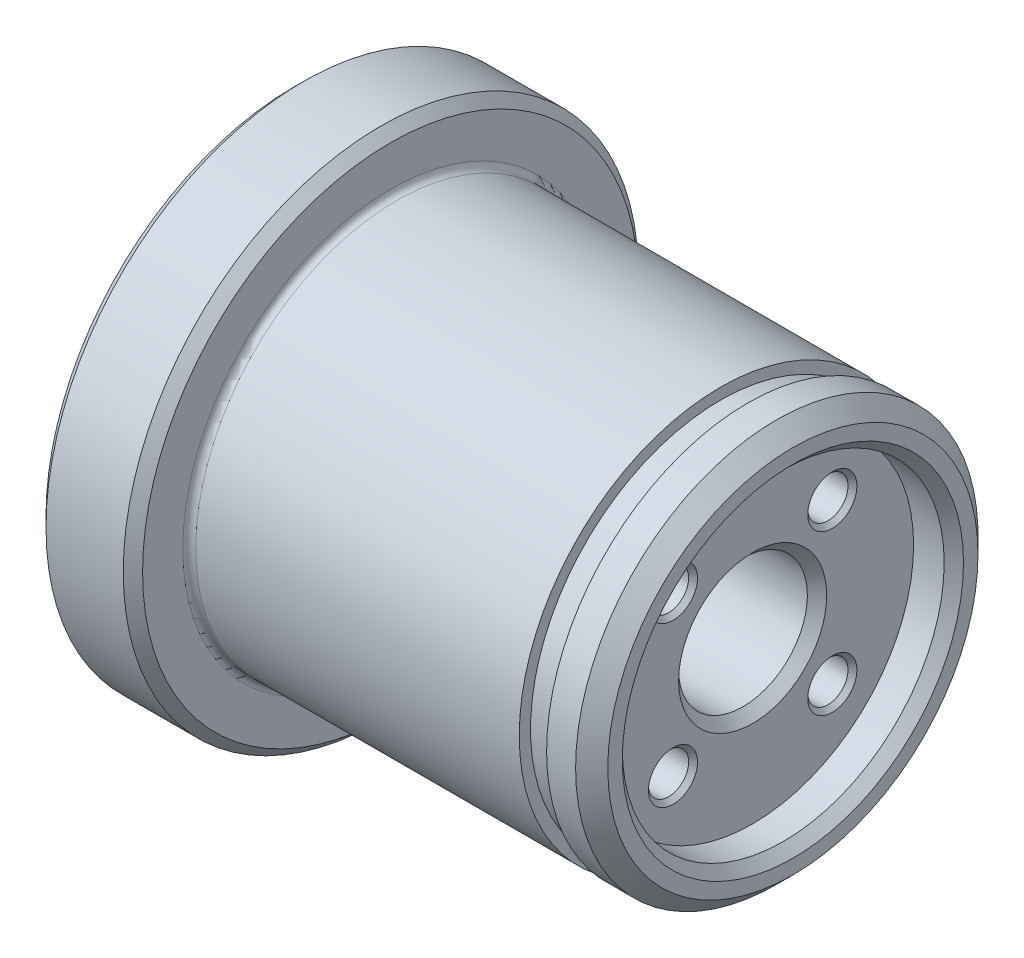
from build123d import *

# Parameters (mm, degrees)
SKETCH_2_W               = 1.7
SKETCH_2_H               = 0.7
CHAMFER_1_SIZE           = 1
FILLET_1_R               = 0.4
SKETCH_5_W               = 2.5
SKETCH_5_H               = 10
PATTERN_CIRCULAR_1_COUNT = 4
CHAMFER_2_SIZE           = 0.6
SKETCH_6_W               = 31
SKETCH_6_H               = 4
CHAMFER_3_SIZE           = 0.6
PATTERN_CIRCULAR_2_COUNT = 4
CHAMFER_4_SIZE           = 0.6


with BuildPart() as part:
    # Эскиз1 → Повернуть1 (revolve)
    with BuildSketch(Plane.XY):
        Polygon((0, 0), (0, 12.5), (-25, 12.5), (-25, 16), (-31, 16), (-31, 0), align=None)
    revolve(axis=Axis((0, 0, 0), (1, 0, 0)))

    # Эскиз2 → Вырез-Повернуть1 (revolve, cut)
    with BuildSketch(Plane.XY):
        with Locations((-3.65, 12.15)):
            Rectangle(SKETCH_2_W, SKETCH_2_H)
    revolve(axis=Axis((0, 0, 0), (-1, 0, 0)), mode=Mode.SUBTRACT)

    # Фаска1
    chamfer_1_edges = [part.edges().sort_by_distance(p)[0] for p in [
        (0, -12.5, 0),
    ]]
    chamfer(chamfer_1_edges, length=CHAMFER_1_SIZE)

    # Скругление1
    fillet_1_edges = [part.edges().sort_by_distance(p)[0] for p in [
        (-25, -12.5, 0),
    ]]
    fillet(fillet_1_edges, radius=FILLET_1_R)

    # Эскиз5 → Вырез-Повернуть2 (revolve, cut)
    with BuildSketch(Plane.XY):
        with Locations((-1.25, 5)):
            Rectangle(SKETCH_5_W, SKETCH_5_H)
    revolve(axis=Axis((0, 0, 0), (-1, 0, 0)), mode=Mode.SUBTRACT)

    # Эскиз4 → Отверстие обработанное метчиком M31 (revolve, cut)
    with BuildSketch(Plane(origin=(-2.5, 4.949747468, -4.949747468), x_dir=(0, 0, -1), z_dir=(0, 1, 0))):
        Polygon((0, 0), (0, 7.751075774), (1.25, 7), (1.25, 0.275), (1.525, 0), align=None)
    hole_wizard_m31 = revolve(axis=Axis((3.85, 4.949747468, -4.949747468), (-1, 0, 0)), mode=Mode.SUBTRACT)

    # Круговой массив1: Отверстие обработанное метчиком M31 ×4 about axis
    pattern_circular_1_axis = Axis((0, 0, 0), (1, 0, 0))
    for i in range(1, PATTERN_CIRCULAR_1_COUNT):
        add(hole_wizard_m31.rotate(pattern_circular_1_axis, i * 360 / PATTERN_CIRCULAR_1_COUNT), mode=Mode.SUBTRACT)

    # Фаска2
    chamfer_2_edges = [part.edges().sort_by_distance(p)[0] for p in [
        (0, -10, 0),
    ]]
    chamfer(chamfer_2_edges, length=CHAMFER_2_SIZE)

    # Эскиз6 → Вырез-Повернуть3 (revolve, cut)
    with BuildSketch(Plane.XY):
        with Locations((-15.5, 2)):
            Rectangle(SKETCH_6_W, SKETCH_6_H)
    revolve(axis=Axis((0, 0, 0), (-1, 0, 0)), mode=Mode.SUBTRACT)

    # Фаска3
    chamfer_3_edges = [part.edges().sort_by_distance(p)[0] for p in [
        (-31, -4, 0),
        (-2.5, -4, 0),
    ]]
    chamfer(chamfer_3_edges, length=CHAMFER_3_SIZE)

    # Эскиз8 → Отверстие обработанное метчиком M32 (revolve, cut)
    with BuildSketch(Plane(origin=(-31, 7.071067812, 7.071067812), x_dir=(0, 0, 1), z_dir=(0, 1, 0))):
        Polygon((0, 0), (0, 8.751075774), (1.25, 8), (1.25, 0.275), (1.525, 0), align=None)
    hole_wizard_m32 = revolve(axis=Axis((-37.35, 7.071067812, 7.071067812), (1, 0, 0)), mode=Mode.SUBTRACT)

    # Круговой массив2: Отверстие обработанное метчиком M32 ×4 about axis
    pattern_circular_2_axis = Axis((0, 0, 0), (1, 0, 0))
    for i in range(1, PATTERN_CIRCULAR_2_COUNT):
        add(hole_wizard_m32.rotate(pattern_circular_2_axis, i * 360 / PATTERN_CIRCULAR_2_COUNT), mode=Mode.SUBTRACT)

    # Фаска4
    chamfer_4_edges = [part.edges().sort_by_distance(p)[0] for p in [
        (-31, -16, 0),
        (-25, -16, 0),
    ]]
    chamfer(chamfer_4_edges, length=CHAMFER_4_SIZE)


solid = part.part
